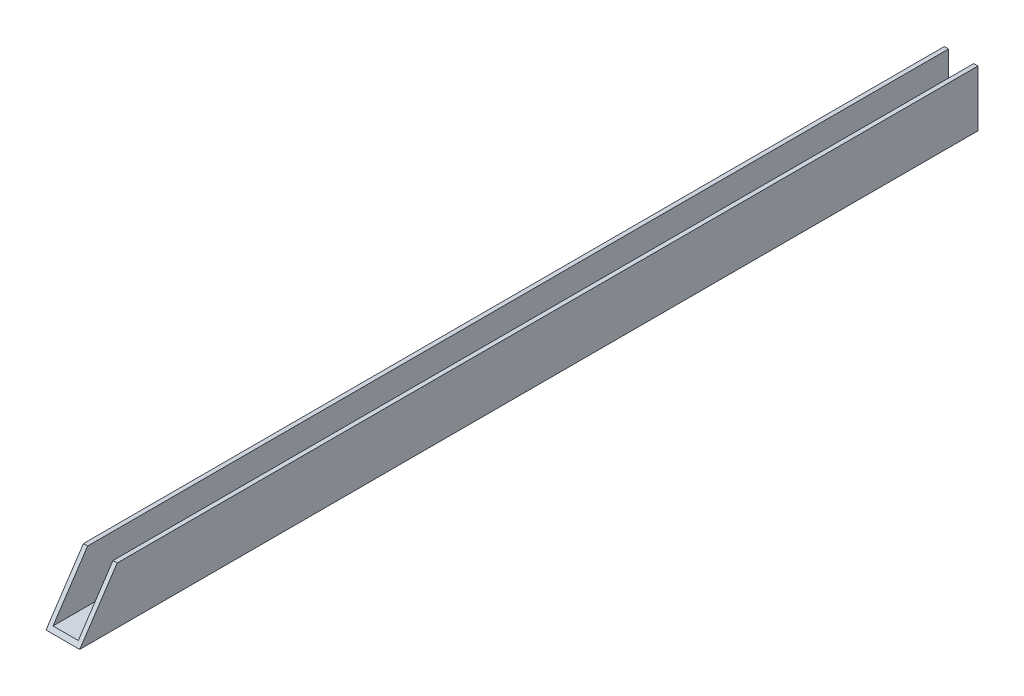
from build123d import *

# Parameters (mm, degrees)
BOSS_EXTRUDE1_DEPTH = 127
CUT_EXTRUDE1_DEPTH  = 10.525


with BuildPart() as part:
    # Sketch1 → Boss-Extrude1 (new body, symmetric)
    with BuildSketch(Plane.XY):
        Polygon((-3.571875, 15.875), (-4.7625, 15.875), (-4.7625, 0), (4.7625, 0), (4.7625, 15.875), (3.571875, 15.875), (3.571875, 1.190625), (-3.571875, 1.190625), align=None)
    extrude(amount=BOSS_EXTRUDE1_DEPTH, both=True)

    # Sketch3 → Cut-Extrude1 (cut, through all)
    with BuildSketch(Plane.ZY.offset(4.7625)):
        Polygon((127, 0), (117.610335596, 14.084496606), (106.170739416, 31.243890876), (157.683078153, 12.341977689), align=None)
    extrude(amount=-CUT_EXTRUDE1_DEPTH, mode=Mode.SUBTRACT)


solid = part.part
